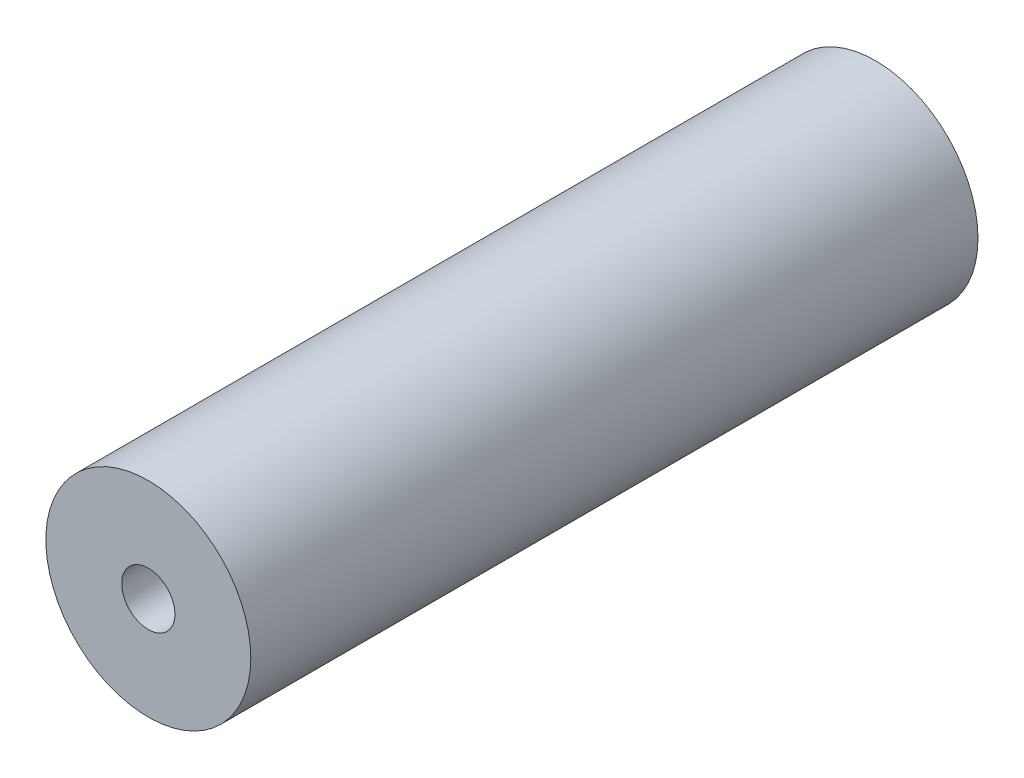
from build123d import *

# Parameters (mm, degrees)
SKIZZE1_R                       = 15.5
SKIZZE1_R_2                     = 4.025
AUFSATZ_LINEAR_AUSTRAGEN1_DEPTH = 110


with BuildPart() as part:
    # Skizze1 → Aufsatz-Linear austragen1 (new body)
    with BuildSketch(Plane.XY):
        Circle(SKIZZE1_R)
        Circle(SKIZZE1_R_2, mode=Mode.SUBTRACT)
    extrude(amount=AUFSATZ_LINEAR_AUSTRAGEN1_DEPTH)


solid = part.part
